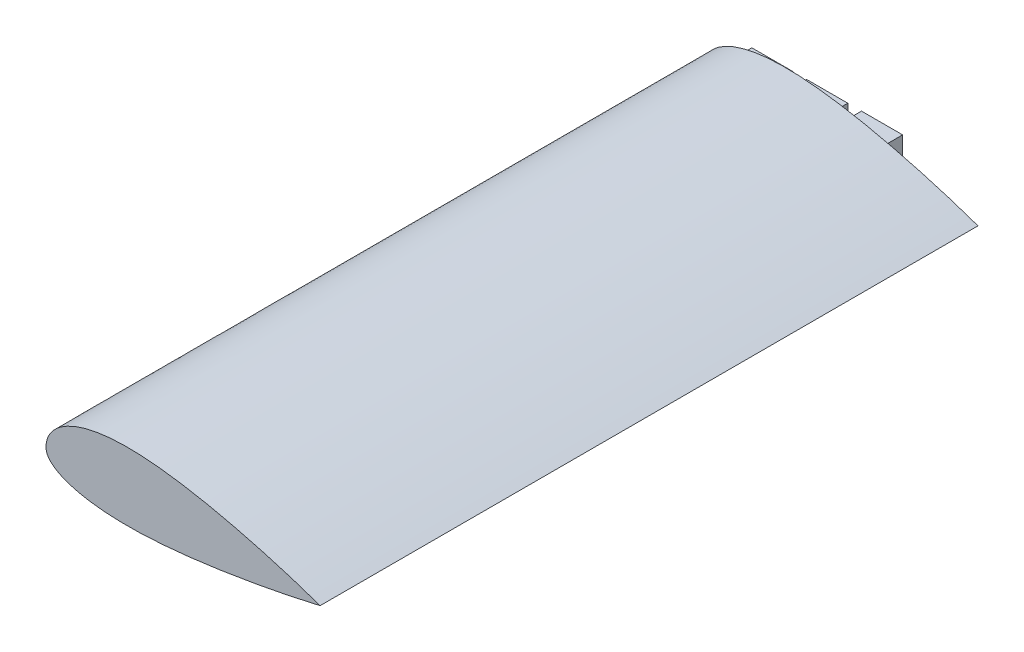
from build123d import *

# Parameters (mm, degrees)
BOSS_EXTRUDE1_DEPTH     = 125
CUT_EXTRUDE1_DEPTH      = 120
CUT_EXTRUDE1_DEPTH_BACK = 110
SKETCH7_OUTSIDE_W       = 156.08
SKETCH7_OUTSIDE_H       = 80.93
SKETCH7_OUTSIDE_W_2     = 15
SKETCH7_OUTSIDE_H_2     = 10
CUT_EXTRUDE2_DEPTH      = 10


with BuildPart() as part:
    # Sketch1 → Boss-Extrude1 (new body, symmetric)
    with BuildSketch(Plane.XY):
        with BuildLine():
            add(Edge.make_bspline(
                [(0, 0), (0.000850995, 0.329659199), (0.029549865, 0.927472015), (0.14385133, 1.796745902), (0.437026819, 2.918116545), (0.854897816, 3.99067399), (1.431457873, 5.075606208), (2.192315162, 6.177305776), (3.200330795, 7.329994922), (4.495933807, 8.510625759), (6.154032841, 9.714948919), (8.274086435, 10.929186229), (10.956963281, 12.114631433), (14.147653492, 13.152534318), (18.040460609, 14.036328853), (23.13432232, 14.736569605), (29.235682959, 15.027445823), (35.337980191, 14.824799668), (41.101061226, 14.313753112), (46.84100573, 13.596774566), (51.603718071, 12.850513756), (56.345578755, 11.983351698), (61.067148387, 11.013921336), (64.832774323, 10.182970339), (68.586460194, 9.301464098), (72.329426272, 8.372556112), (76.059801155, 7.399362237), (79.315748534, 6.509324276), (82.095955547, 5.720960272), (84.412746103, 5.044415193), (86.253737616, 4.495737821), (88.110746108, 3.929395104), (89.928948501, 3.364622885), (91.806033909, 2.766575591), (93.571042413, 2.195551738), (95.520153622, 1.546294126), (97.13830136, 1.000944859), (98.775140125, 0.431667147), (99.586664269, 0.14652965), (100.000220498, 0)],
                knots=[0, 0, 0, 0, 0, 0.011046069, 0.020081733, 0.029325805, 0.03880189, 0.049580055, 0.06120956, 0.074146174, 0.090070544, 0.108265326, 0.129826997, 0.155964864, 0.18830697, 0.220649281, 0.263591413, 0.32827592, 0.392960436, 0.425302696, 0.457644956, 0.52232947, 0.55467173, 0.58701399, 0.619356253, 0.651698515, 0.684040775, 0.716383035, 0.748725291, 0.764896419, 0.781067547, 0.797238677, 0.813409806, 0.829580935, 0.845752065, 0.861923198, 0.878094331, 0.894265464, 0.910433902, 0.910433902, 0.910433902, 0.910433902, 0.910433902], degree=4))
            add(Edge.make_bspline(
                [(0, 0), (0.000283694, -0.169267254), (0.015976794, -0.461371136), (0.077487025, -0.88514164), (0.233270026, -1.435649885), (0.451244669, -1.960918505), (0.763020391, -2.515682909), (1.196819683, -3.111846412), (1.800946429, -3.766711239), (2.645862845, -4.495413172), (3.845009807, -5.315163118), (5.520192869, -6.210587445), (7.890487327, -7.180714875), (10.947062049, -8.096276481), (15.429604607, -9.039640979), (21.207967366, -9.730011133), (27.977535992, -10.02746215), (35.648602876, -9.889128299), (42.346864335, -9.465706657), (48.074827103, -8.93985543), (53.791477179, -8.306095929), (59.496830619, -7.576550222), (65.188499989, -6.746051578), (70.86666832, -5.830240622), (75.589869863, -5.014181774), (79.362447213, -4.33071773), (82.659602016, -3.705830248), (85.480106996, -3.151491524), (87.596226543, -2.723280533), (89.000489113, -2.434123885), (90.181059485, -2.187185496), (91.104029231, -1.992562417), (92.305099816, -1.735390328), (93.655404022, -1.443860687), (95.389810689, -1.059643077), (97.102663756, -0.674849293), (98.714450572, -0.301843412), (99.575627153, -0.100232022), (100.000220498, 0)],
                knots=[0, 0, 0, 0, 0, 0.005887152, 0.010193359, 0.014866851, 0.019889426, 0.025655397, 0.032314697, 0.040497527, 0.050864902, 0.064448179, 0.082823086, 0.106555664, 0.139953895, 0.175459216, 0.242255956, 0.309052716, 0.375849477, 0.442646237, 0.47604462, 0.509443003, 0.576239764, 0.643036527, 0.676434909, 0.709833291, 0.743231671, 0.77663005, 0.793329242, 0.810028433, 0.818378029, 0.826727624, 0.83507722, 0.843426816, 0.860126007, 0.876825198, 0.893524389, 0.91022358, 0.91022358, 0.91022358, 0.91022358, 0.91022358], degree=4))
        make_face()
    extrude(amount=BOSS_EXTRUDE1_DEPTH, both=True)

    # Sketch6 → Cut-Extrude1 (cut, two sides)
    with BuildSketch(Plane.XY) as cut_extrude1_sk:
        with BuildLine():
            add(Edge.make_bspline(
                [(5.003866411, 0.16593331), (5.021771107, 0.603167174), (5.179582681, 1.45668418), (5.828059264, 2.731623867), (6.970434665, 4.055197794), (9.059941641, 5.70999826), (12.439790451, 7.406031049), (17.102385774, 8.772586441), (22.086939339, 9.580996278), (28.969887571, 10.04915127), (37.811358565, 9.719164197), (48.519550578, 8.365627259), (62.800967104, 5.688073766), (73.468720144, 2.987314718), (80.492223408, 0.975075783)],
                knots=[0.003107056, 0.003107056, 0.003107056, 0.003107056, 0.026472192, 0.049837329, 0.073202466, 0.096567602, 0.143297876, 0.190028149, 0.236758422, 0.283488695, 0.376949242, 0.470409788, 0.563870335, 0.750791428, 0.750791428, 0.750791428, 0.750791428], degree=3))
            add(Edge.make_bspline(
                [(80.492223408, 0.975075783), (73.808709309, -0.294311553), (63.724097701, -1.995472923), (50.2739718, -3.721966825), (40.201550005, -4.64981718), (31.854573956, -4.99623266), (25.257558055, -4.894657534), (20.376304938, -4.583057975), (16.407020376, -4.077297068), (13.341823588, -3.482519629), (11.126614852, -2.928004065), (9.036775347, -2.250698534), (7.465669402, -1.576012545), (6.39422808, -0.985208256), (5.718999313, -0.532122097), (5.309123649, -0.182799424), (5.089567118, 0.053028449), (5.034725373, 0.122545069), (5.003866411, 0.16593331)],
                knots=[0.025550827, 0.025550827, 0.025550827, 0.025550827, 0.20536823, 0.295276931, 0.385185632, 0.475094334, 0.520048685, 0.565003035, 0.609957386, 0.632434561, 0.654911737, 0.677388912, 0.699866088, 0.711104675, 0.722343263, 0.733581851, 0.739201144, 0.744820438, 0.744820438, 0.744820438, 0.744820438], degree=3))
        make_face()
    extrude(amount=CUT_EXTRUDE1_DEPTH, mode=Mode.SUBTRACT)
    extrude(cut_extrude1_sk.sketch, amount=-CUT_EXTRUDE1_DEPTH_BACK, mode=Mode.SUBTRACT)

    # Sketch7 outside → Cut-Extrude2 (cut)
    with BuildSketch(Plane(origin=(0, 0, -125), x_dir=(-1, 0, 0), z_dir=(0, 0, -1))):
        with Locations((-50, 2.485)):
            Rectangle(SKETCH7_OUTSIDE_W, SKETCH7_OUTSIDE_H)
        with Locations((-15, 0)):
            Rectangle(SKETCH7_OUTSIDE_W_2, SKETCH7_OUTSIDE_H_2, mode=Mode.SUBTRACT)
        with Locations((-35, 0)):
            Rectangle(SKETCH7_OUTSIDE_W_2, SKETCH7_OUTSIDE_H_2, mode=Mode.SUBTRACT)
        with Locations((-55, 0)):
            Rectangle(SKETCH7_OUTSIDE_W_2, SKETCH7_OUTSIDE_H_2, mode=Mode.SUBTRACT)
    extrude(amount=-CUT_EXTRUDE2_DEPTH, mode=Mode.SUBTRACT)


solid = part.part
